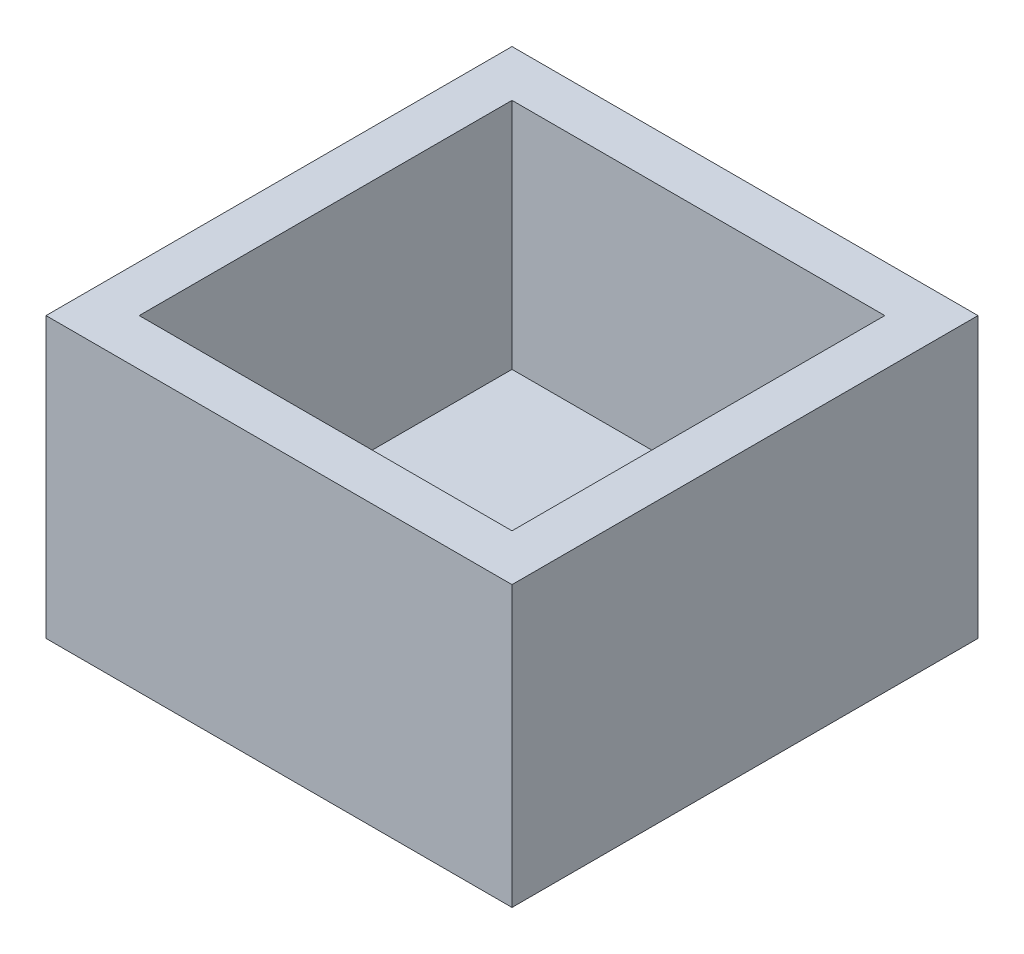
from build123d import *

# Parameters (mm, degrees)
SKETCH1_W           = 10
SKETCH1_H           = 10
BOSS_EXTRUDE1_DEPTH = 1
SKETCH2_W           = 10
SKETCH2_H           = 10
SKETCH2_W_2         = 8
SKETCH2_H_2         = 8
BOSS_EXTRUDE2_DEPTH = 5


with BuildPart() as part:
    # Sketch1 → Boss-Extrude1 (new body)
    with BuildSketch(Plane(origin=(0, 0, 0), x_dir=(1, 0, 0), z_dir=(0, 1, 0))):
        with Locations((5, -5)):
            Rectangle(SKETCH1_W, SKETCH1_H)
    extrude(amount=BOSS_EXTRUDE1_DEPTH)

    # Sketch2 → Boss-Extrude2 (add)
    with BuildSketch(Plane(origin=(0, 1, 0), x_dir=(1, 0, 0), z_dir=(0, 1, 0))):
        with Locations((5, -5)):
            Rectangle(SKETCH2_W, SKETCH2_H)
        with Locations((5, -5)):
            Rectangle(SKETCH2_W_2, SKETCH2_H_2, mode=Mode.SUBTRACT)
    extrude(amount=BOSS_EXTRUDE2_DEPTH)


solid = part.part
